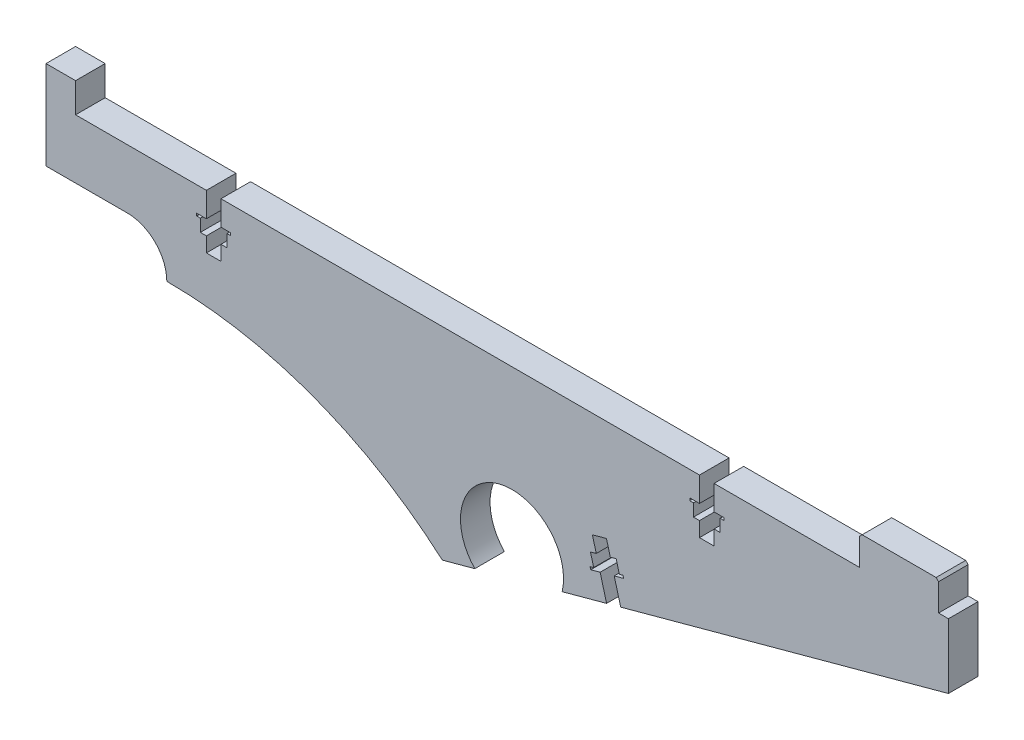
from build123d import *

# Parameters (mm, degrees)
BOSS_EXTRUDE1_DEPTH = 6
CHAMFER2_SIZE       = 0.5
CUT_EXTRUDE1_DEPTH  = 7


with BuildPart() as part:
    # Sketch1 → Boss-Extrude1 (new body)
    with BuildSketch(Plane.XY):
        with BuildLine():
            Line((116.02, 20), (116.02, 15))
            Line((116.02, 15), (114.05, 15))
            Line((114.05, 15), (114.05, 14.5))
            Line((114.05, 14.5), (114.8, 14.5))
            Line((114.8, 14.5), (114.8, 12))
            Line((114.8, 12), (116.02, 12))
            Line((116.02, 12), (116.02, 9))
            Line((116.02, 9), (118.98, 9))
            Line((118.98, 9), (118.98, 12))
            Line((118.98, 12), (120.2, 12))
            Line((120.2, 12), (120.2, 14.5))
            Line((120.2, 14.5), (120.95, 14.5))
            Line((120.95, 14.5), (120.95, 15))
            Line((120.95, 15), (118.98, 15))
            Line((118.98, 15), (118.98, 20))
            Line((118.98, 20), (148.5, 20))
            Line((148.5, 20), (148.5, 26))
            Line((148.5, 26), (164.5, 26))
            Line((164.5, 26), (164.5, 20))
            Line((164.5, 20), (166.5, 20))
            Line((166.5, 20), (166.5, 6.863840125))
            Line((166.5, 6.863840125), (88.166127224, -14.419164582))
            ThreePointArc((88.166127224, -14.419164582), (75.2601036, -1.915582926), (70.455783207, -19.230995297))
            Line((70.455783207, -19.230995297), (63.870699409, -21.020136629))
            ThreePointArc((63.870699409, -21.020136629), (37.847031663, -5.428892585), (8, 0))
            ThreePointArc((8, 0), (5.656854017, 5.656854482), (-6.59e-07, 8))
            Line((-6.59e-07, 8), (-16.5, 8))
            Line((-16.5, 8), (-16.5, 26))
            Line((-16.5, 26), (-10.5, 26))
            Line((-10.5, 26), (-10.5, 20))
            Line((-10.5, 20), (16.02, 20))
            Line((16.02, 20), (16.02, 15))
            Line((16.02, 15), (14.05, 15))
            Line((14.05, 15), (14.05, 14.5))
            Line((14.05, 14.5), (14.8, 14.5))
            Line((14.8, 14.5), (14.8, 12))
            Line((14.8, 12), (16.02, 12))
            Line((16.02, 12), (16.02, 9))
            Line((16.02, 9), (18.98, 9))
            Line((18.98, 9), (18.98, 12))
            Line((18.98, 12), (20.2, 12))
            Line((20.2, 12), (20.2, 14.5))
            Line((20.2, 14.5), (20.95, 14.5))
            Line((20.95, 14.5), (20.95, 15))
            Line((20.95, 15), (18.98, 15))
            Line((18.98, 15), (18.98, 20))
            Line((18.98, 20), (116.02, 20))
        make_face()
    extrude(amount=BOSS_EXTRUDE1_DEPTH)

    # Chamfer2
    chamfer2_edges = [part.edges().sort_by_distance(p)[0] for p in [
        (148.5, 26, 3),
        (164.5, 26, 3),
    ]]
    chamfer(chamfer2_edges, length=CHAMFER2_SIZE)

    # Sketch2 → Cut-Extrude1 (cut, through all)
    with BuildSketch(Plane.XY.offset(6)):
        Polygon((100.039498636, -11.193216334), (97.183051312, -11.969301821), (95.872096096, -7.144221882), (93.9710146, -7.660738237), (93.839919078, -7.178230243), (94.563681069, -6.981586961), (93.908203462, -4.569046991), (95.085522967, -4.249173918), (94.298949838, -1.354125954), (97.155397162, -0.578040467), (97.941970291, -3.473088431), (99.119289796, -3.153215358), (99.774767404, -5.565755328), (100.498529395, -5.369112046), (100.629624916, -5.851620039), (98.72854342, -6.368136394), align=None)
    extrude(amount=-CUT_EXTRUDE1_DEPTH, mode=Mode.SUBTRACT)


solid = part.part
